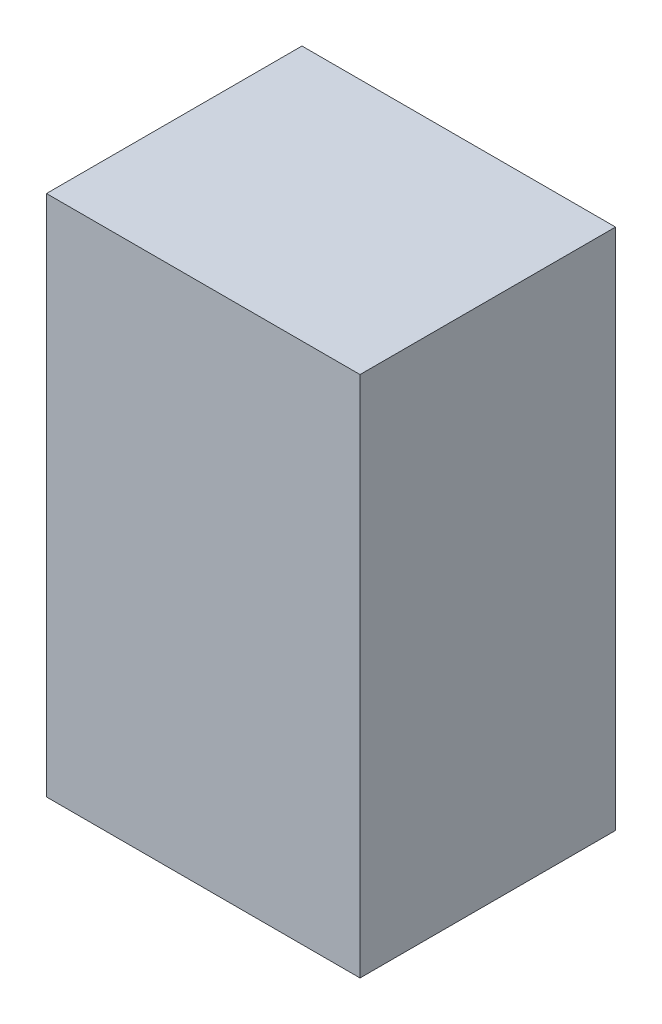
from build123d import *

# Parameters (mm, degrees)
SKETCH1_W           = 54
SKETCH1_H           = 90
SKETCH1_W_2         = 38
SKETCH1_H_2         = 74
BOSS_EXTRUDE1_DEPTH = 40
CUT_EXTRUDE1_DEPTH  = 4.1
CUT_EXTRUDE2_DEPTH  = 0.5
CUT_EXTRUDE3_DEPTH  = 4.1
SKETCH7_R           = 4.1
CUT_EXTRUDE4_DEPTH  = 0.5
SKETCH8_W           = 54
SKETCH8_H           = 90
BOSS_EXTRUDE2_DEPTH = 2
SKETCH9_W           = 54
SKETCH9_H           = 90
BOSS_EXTRUDE3_DEPTH = 2


with BuildPart() as part:
    # Sketch1 → Boss-Extrude1 (new body)
    with BuildSketch(Plane.XY):
        with Locations((27, 45)):
            Rectangle(SKETCH1_W, SKETCH1_H)
        with Locations((27, 45)):
            Rectangle(SKETCH1_W_2, SKETCH1_H_2, mode=Mode.SUBTRACT)
    extrude(amount=BOSS_EXTRUDE1_DEPTH)

    # Sketch2 → Cut-Extrude1 (cut)
    with BuildSketch(Plane.ZY.offset(-46)):
        Polygon((25.888972746, 63), (22.944486373, 68.1), (17.055513627, 68.1), (14.111027254, 63), (17.055513627, 57.9), (22.944486373, 57.9), align=None)
        Polygon((25.888972746, 27), (22.944486373, 32.1), (17.055513627, 32.1), (14.111027254, 27), (17.055513627, 21.9), (22.944486373, 21.9), align=None)
    extrude(amount=-CUT_EXTRUDE1_DEPTH, mode=Mode.SUBTRACT)

    # Sketch5 → Cut-Extrude2 (cut)
    with BuildSketch(Plane.ZY.offset(-50.1)):
        Polygon((17.632863896, 22.9), (22.367136104, 22.9), (24.734272207, 27), (22.367136104, 31.1), (17.632863896, 31.1), (15.265727793, 27), align=None)
        Polygon((24.734272207, 63), (22.367136104, 67.1), (17.632863896, 67.1), (15.265727793, 63), (17.632863896, 58.9), (22.367136104, 58.9), align=None)
    extrude(amount=-CUT_EXTRUDE2_DEPTH, mode=Mode.SUBTRACT)

    # Sketch6 → Cut-Extrude3 (cut)
    with BuildSketch(Plane(origin=(8, 0, 0), x_dir=(0, 0, -1), z_dir=(1, 0, 0))):
        Polygon((-14.111027254, 63), (-17.055513627, 68.1), (-22.944486373, 68.1), (-25.888972746, 63), (-22.944486373, 57.9), (-17.055513627, 57.9), align=None)
        Polygon((-14.111027254, 27), (-17.055513627, 32.1), (-22.944486373, 32.1), (-25.888972746, 27), (-22.944486373, 21.9), (-17.055513627, 21.9), align=None)
    extrude(amount=-CUT_EXTRUDE3_DEPTH, mode=Mode.SUBTRACT)

    # Sketch7 → Cut-Extrude4 (cut)
    with BuildSketch(Plane(origin=(3.9, 0, 0), x_dir=(0, 0, -1), z_dir=(1, 0, 0))):
        with Locations((-20, 63)):
            Circle(SKETCH7_R)
        with Locations((-20, 27)):
            Circle(SKETCH7_R)
    extrude(amount=-CUT_EXTRUDE4_DEPTH, mode=Mode.SUBTRACT)

    # Sketch8 → Boss-Extrude2 (add)
    with BuildSketch(Plane.XY.offset(40)):
        with Locations((27, 45)):
            Rectangle(SKETCH8_W, SKETCH8_H)
    extrude(amount=BOSS_EXTRUDE2_DEPTH)

    # Sketch9 → Boss-Extrude3 (add)
    with BuildSketch(Plane(origin=(0, 0, 0), x_dir=(-1, 0, 0), z_dir=(0, 0, -1))):
        with Locations((-27, 45)):
            Rectangle(SKETCH9_W, SKETCH9_H)
    extrude(amount=BOSS_EXTRUDE3_DEPTH)


solid = part.part
